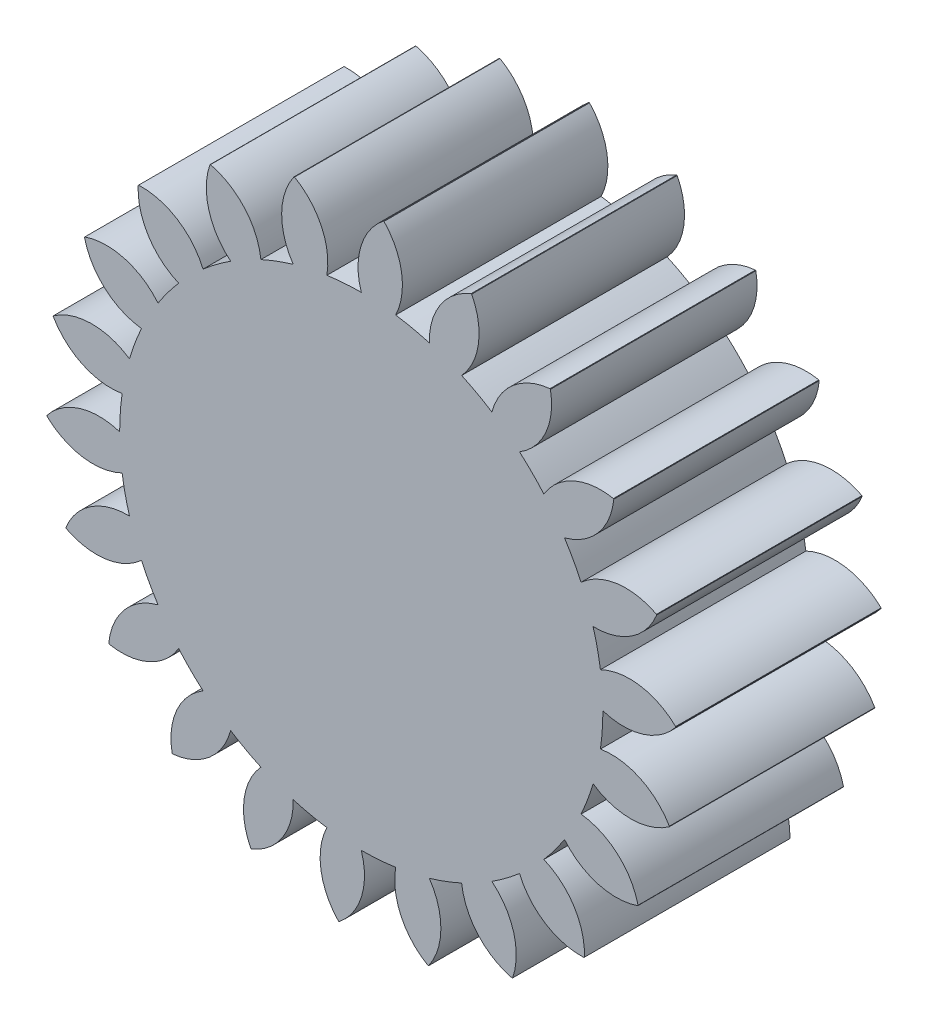
from build123d import *

# Parameters (mm, degrees)
BOSS_EXTRUDE1_DEPTH = 4
CUT_EXTRUDE1_DEPTH  = 10


with BuildPart() as part:
    # Sketch1 → Boss-Extrude1 (new body)
    with BuildSketch(Plane.XY):
        with BuildLine():
            ThreePointArc((0.432215106, 6.121703644), (-0.006111672, 5.480502071), (0, 4.703821656))
            ThreePointArc((0, 4.703821656), (-0.335566795, 4.691836858), (-0.669423618, 4.655943534))
            ThreePointArc((-0.669423618, 4.655943534), (-0.773907302, 5.425588244), (-1.299025043, 5.997882904))
            ThreePointArc((-1.299025043, 5.997882904), (0.437804478, -6.121306449), (0.432215106, 6.121703644))
        make_face()
    extrude(amount=BOSS_EXTRUDE1_DEPTH)

    # Sketch2 → Cut-Extrude1 (cut)
    with BuildSketch(Plane.XY.offset(4)):
        with BuildLine():
            ThreePointArc((-3.554911214, 3.080348102), (-4.145889401, 3.584346716), (-4.343434222, 4.335509723))
            ThreePointArc((-4.343434222, 4.335509723), (-4.912875705, 3.677732686), (-5.383577945, 2.946040378))
            ThreePointArc((-5.383577945, 2.946040378), (-4.60718751, 2.968124585), (-3.957106586, 2.543077985))
            ThreePointArc((-3.957106586, 2.543077985), (-3.765603226, 2.818895266), (-3.554911214, 3.080348102))
        make_face()
        with BuildLine():
            ThreePointArc((-2.543077985, 3.957106586), (-2.968124585, 4.60718751), (-2.946040378, 5.383577945))
            ThreePointArc((-2.946040378, 5.383577945), (-3.677732686, 4.912875705), (-4.335509723, 4.343434222))
            ThreePointArc((-4.335509723, 4.343434222), (-3.584346716, 4.145889401), (-3.080348102, 3.554911214))
            ThreePointArc((-3.080348102, 3.554911214), (-2.818895266, 3.765603226), (-2.543077985, 3.957106586))
        make_face()
        with BuildLine():
            ThreePointArc((-1.325219702, 4.513283828), (-1.549899967, 5.256781372), (-1.309975863, 5.995500699))
            ThreePointArc((-1.309975863, 5.995500699), (-2.144641637, 5.750006752), (-2.936204288, 5.388948857))
            ThreePointArc((-2.936204288, 5.388948857), (-2.271123467, 4.987778915), (-1.954038134, 4.278746679))
            ThreePointArc((-1.954038134, 4.278746679), (-1.643817176, 4.407244407), (-1.325219702, 4.513283828))
        make_face()
        with BuildLine():
            ThreePointArc((2.139390577, 5.751962566), (1.304500997, 5.996694302), (0.443393485, 6.12090415))
            ThreePointArc((0.443393485, 6.12090415), (0.78600623, 5.423848681), (0.669423618, 4.655943534))
            ThreePointArc((0.669423618, 4.655943534), (0.999869212, 4.596324589), (1.325219702, 4.513283828))
            ThreePointArc((1.325219702, 4.513283828), (1.538171755, 5.260225086), (2.139390577, 5.751962566))
        make_face()
        with BuildLine():
            ThreePointArc((3.673245347, 4.916231689), (2.941123559, 5.386265646), (2.14989091, 5.748046144))
            ThreePointArc((2.14989091, 5.748046144), (2.282242211, 4.982701155), (1.954038134, 4.278746679))
            ThreePointArc((1.954038134, 4.278746679), (2.254301762, 4.128445438), (2.543077985, 3.957106586))
            ThreePointArc((2.543077985, 3.957106586), (2.957841655, 4.613795948), (3.673245347, 4.916231689))
        make_face()
        with BuildLine():
            ThreePointArc((4.909515624, 3.682216959), (4.339473781, 4.339473781), (3.682216959, 4.909515624))
            ThreePointArc((3.682216959, 4.909515624), (3.593584502, 4.137884814), (3.080348102, 3.554911214))
            ThreePointArc((3.080348102, 3.554911214), (3.32610419, 3.32610419), (3.554911214, 3.080348102))
            ThreePointArc((3.554911214, 3.080348102), (4.137884814, 3.593584502), (4.909515624, 3.682216959))
        make_face()
        with BuildLine():
            ThreePointArc((5.748046144, 2.14989091), (5.386265646, 2.941123559), (4.916231689, 3.673245347))
            ThreePointArc((4.916231689, 3.673245347), (4.613795948, 2.957841655), (3.957106586, 2.543077985))
            ThreePointArc((3.957106586, 2.543077985), (4.128445438, 2.254301762), (4.278746679, 1.954038134))
            ThreePointArc((4.278746679, 1.954038134), (4.982701155, 2.282242211), (5.748046144, 2.14989091))
        make_face()
        with BuildLine():
            ThreePointArc((6.12090415, 0.443393485), (5.996694302, 1.304500997), (5.751962566, 2.139390577))
            ThreePointArc((5.751962566, 2.139390577), (5.260225086, 1.538171755), (4.513283828, 1.325219702))
            ThreePointArc((4.513283828, 1.325219702), (4.596324589, 0.999869212), (4.655943534, 0.669423618))
            ThreePointArc((4.655943534, 0.669423618), (5.423848681, 0.78600623), (6.12090415, 0.443393485))
        make_face()
        with BuildLine():
            ThreePointArc((5.997882904, -1.299025043), (6.121306449, -0.437804478), (6.121703644, 0.432215106))
            ThreePointArc((6.121703644, 0.432215106), (5.480502071, -0.006111672), (4.703821656, 0))
            ThreePointArc((4.703821656, 0), (4.691836858, -0.335566795), (4.655943534, -0.669423618))
            ThreePointArc((4.655943534, -0.669423618), (5.425588244, -0.773907302), (5.997882904, -1.299025043))
        make_face()
        with BuildLine():
            ThreePointArc((5.388948857, -2.936204288), (5.750006752, -2.144641637), (5.995500699, -1.309975863))
            ThreePointArc((5.995500699, -1.309975863), (5.256781372, -1.549899967), (4.513283828, -1.325219702))
            ThreePointArc((4.513283828, -1.325219702), (4.407244407, -1.643817176), (4.278746679, -1.954038134))
            ThreePointArc((4.278746679, -1.954038134), (4.987778915, -2.271123467), (5.388948857, -2.936204288))
        make_face()
        with BuildLine():
            ThreePointArc((4.343434222, -4.335509723), (4.912875705, -3.677732686), (5.383577945, -2.946040378))
            ThreePointArc((5.383577945, -2.946040378), (4.60718751, -2.968124585), (3.957106586, -2.543077985))
            ThreePointArc((3.957106586, -2.543077985), (3.765603226, -2.818895266), (3.554911214, -3.080348102))
            ThreePointArc((3.554911214, -3.080348102), (4.145889401, -3.584346716), (4.343434222, -4.335509723))
        make_face()
        with BuildLine():
            ThreePointArc((2.946040378, -5.383577945), (3.677732686, -4.912875705), (4.335509723, -4.343434222))
            ThreePointArc((4.335509723, -4.343434222), (3.584346716, -4.145889401), (3.080348102, -3.554911214))
            ThreePointArc((3.080348102, -3.554911214), (2.818895266, -3.765603226), (2.543077985, -3.957106586))
            ThreePointArc((2.543077985, -3.957106586), (2.968124585, -4.60718751), (2.946040378, -5.383577945))
        make_face()
        with BuildLine():
            ThreePointArc((1.309975863, -5.995500699), (2.144641637, -5.750006752), (2.936204288, -5.388948857))
            ThreePointArc((2.936204288, -5.388948857), (2.271123467, -4.987778915), (1.954038134, -4.278746679))
            ThreePointArc((1.954038134, -4.278746679), (1.643817176, -4.407244407), (1.325219702, -4.513283828))
            ThreePointArc((1.325219702, -4.513283828), (1.549899967, -5.256781372), (1.309975863, -5.995500699))
        make_face()
        with BuildLine():
            ThreePointArc((0, -4.703821656), (0.006111672, -5.480502071), (-0.432215106, -6.121703644))
            ThreePointArc((-0.432215106, -6.121703644), (0.437804478, -6.121306449), (1.299025043, -5.997882904))
            ThreePointArc((1.299025043, -5.997882904), (0.773907302, -5.425588244), (0.669423618, -4.655943534))
            ThreePointArc((0.669423618, -4.655943534), (0.335566795, -4.691836858), (0, -4.703821656))
        make_face()
        with BuildLine():
            ThreePointArc((-1.325219702, -4.513283828), (-1.538171755, -5.260225086), (-2.139390577, -5.751962566))
            ThreePointArc((-2.139390577, -5.751962566), (-1.304500997, -5.996694302), (-0.443393485, -6.12090415))
            ThreePointArc((-0.443393485, -6.12090415), (-0.78600623, -5.423848681), (-0.669423618, -4.655943534))
            ThreePointArc((-0.669423618, -4.655943534), (-0.999869212, -4.596324589), (-1.325219702, -4.513283828))
        make_face()
        with BuildLine():
            ThreePointArc((-2.543077985, -3.957106586), (-2.957841655, -4.613795948), (-3.673245347, -4.916231689))
            ThreePointArc((-3.673245347, -4.916231689), (-2.941123559, -5.386265646), (-2.14989091, -5.748046144))
            ThreePointArc((-2.14989091, -5.748046144), (-2.282242211, -4.982701155), (-1.954038134, -4.278746679))
            ThreePointArc((-1.954038134, -4.278746679), (-2.254301762, -4.128445438), (-2.543077985, -3.957106586))
        make_face()
        with BuildLine():
            ThreePointArc((-3.554911214, -3.080348102), (-4.137884814, -3.593584502), (-4.909515624, -3.682216959))
            ThreePointArc((-4.909515624, -3.682216959), (-4.339473781, -4.339473781), (-3.682216959, -4.909515624))
            ThreePointArc((-3.682216959, -4.909515624), (-3.593584502, -4.137884814), (-3.080348102, -3.554911214))
            ThreePointArc((-3.080348102, -3.554911214), (-3.32610419, -3.32610419), (-3.554911214, -3.080348102))
        make_face()
        with BuildLine():
            ThreePointArc((-4.278746679, -1.954038134), (-4.982701155, -2.282242211), (-5.748046144, -2.14989091))
            ThreePointArc((-5.748046144, -2.14989091), (-5.386265646, -2.941123559), (-4.916231689, -3.673245347))
            ThreePointArc((-4.916231689, -3.673245347), (-4.613795948, -2.957841655), (-3.957106586, -2.543077985))
            ThreePointArc((-3.957106586, -2.543077985), (-4.128445438, -2.254301762), (-4.278746679, -1.954038134))
        make_face()
        with BuildLine():
            ThreePointArc((-4.655943534, -0.669423618), (-5.423848681, -0.78600623), (-6.12090415, -0.443393485))
            ThreePointArc((-6.12090415, -0.443393485), (-5.996694302, -1.304500997), (-5.751962566, -2.139390577))
            ThreePointArc((-5.751962566, -2.139390577), (-5.260225086, -1.538171755), (-4.513283828, -1.325219702))
            ThreePointArc((-4.513283828, -1.325219702), (-4.596324589, -0.999869212), (-4.655943534, -0.669423618))
        make_face()
        with BuildLine():
            ThreePointArc((-4.655943534, 0.669423618), (-5.425588244, 0.773907302), (-5.997882904, 1.299025043))
            ThreePointArc((-5.997882904, 1.299025043), (-6.121306449, 0.437804478), (-6.121703644, -0.432215106))
            ThreePointArc((-6.121703644, -0.432215106), (-5.480502071, 0.006111672), (-4.703821656, 0))
            ThreePointArc((-4.703821656, 0), (-4.691836858, 0.335566795), (-4.655943534, 0.669423618))
        make_face()
        with BuildLine():
            ThreePointArc((-4.278746679, 1.954038134), (-4.987778915, 2.271123467), (-5.388948857, 2.936204288))
            ThreePointArc((-5.388948857, 2.936204288), (-5.750006752, 2.144641637), (-5.995500699, 1.309975863))
            ThreePointArc((-5.995500699, 1.309975863), (-5.256781372, 1.549899967), (-4.513283828, 1.325219702))
            ThreePointArc((-4.513283828, 1.325219702), (-4.407244407, 1.643817176), (-4.278746679, 1.954038134))
        make_face()
    extrude(amount=-CUT_EXTRUDE1_DEPTH, mode=Mode.SUBTRACT)


solid = part.part
